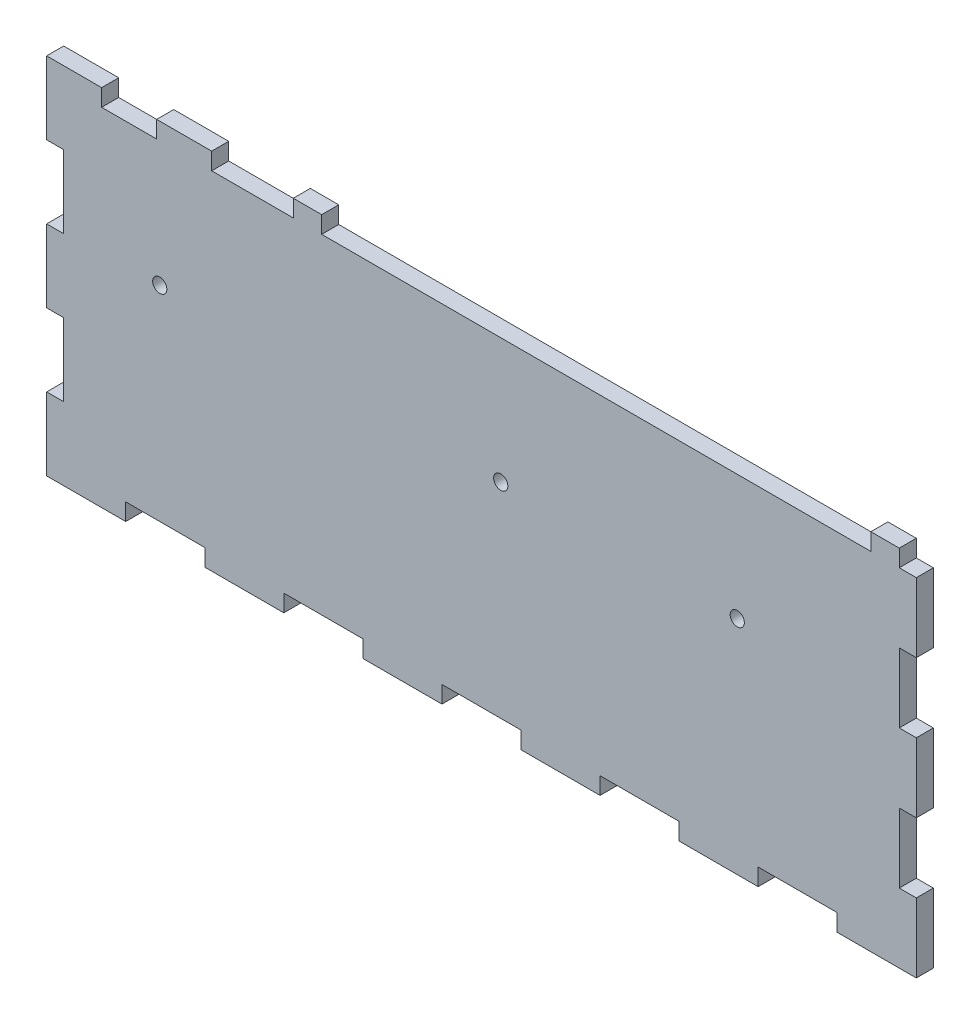
from build123d import *

# Parameters (mm, degrees)
CROQUIS1_R              = 1.25
SALIENTE_EXTRUIR1_DEPTH = 3


with BuildPart() as part:
    # Croquis1 → Saliente-Extruir1 (new body)
    with BuildSketch(Plane.XY):
        Polygon((96.61, -16.741574692), (0, -16.741574692), (0, -13.741574692), (-5, -13.741574692), (-5, -16.741574692), (-9.678, -16.741574692), (-19.356, -16.741574692), (-19.356, -13.741574692), (-29.034, -13.741574692), (-29.034, -16.741574692), (-38.712, -16.741574692), (-38.712, -13.741574692), (-48.39, -13.741574692), (-48.39, -26.541574692), (-45.39, -26.541574692), (-45.39, -39.341574692), (-48.39, -39.341574692), (-48.39, -52.141574692), (-45.39, -52.141574692), (-45.39, -64.941574692), (-48.39, -64.941574692), (-48.39, -77.741574692), (-34.480909091, -77.741574692), (-34.480909091, -74.741574692), (-20.571818182, -74.741574692), (-20.571818182, -77.741574692), (-6.662727273, -77.741574692), (-6.662727273, -74.741574692), (7.246363636, -74.741574692), (7.246363636, -77.741574692), (21.155454545, -77.741574692), (21.155454545, -74.741574692), (35.064545455, -74.741574692), (35.064545455, -77.741574692), (48.973636364, -77.741574692), (48.973636364, -74.741574692), (62.882727273, -74.741574692), (62.882727273, -77.741574692), (76.791818182, -77.741574692), (76.791818182, -74.741574692), (90.700909091, -74.741574692), (90.700909091, -77.741574692), (104.61, -77.741574692), (104.61, -65.541574692), (101.61, -65.541574692), (101.61, -53.341574692), (104.61, -53.341574692), (104.61, -41.141574692), (101.61, -41.141574692), (101.61, -28.941574692), (104.61, -28.941574692), (104.61, -16.741574692), (101.61, -16.741574692), (101.61, -13.741574692), (96.61, -13.741574692), align=None)
        with Locations((-28.49, -38.741574692)):
            Circle(CROQUIS1_R, mode=Mode.SUBTRACT)
        with Locations((31.5, -38.741574692)):
            Circle(CROQUIS1_R, mode=Mode.SUBTRACT)
        with Locations((73.11, -38.741574692)):
            Circle(CROQUIS1_R, mode=Mode.SUBTRACT)
    extrude(amount=SALIENTE_EXTRUIR1_DEPTH)


solid = part.part
